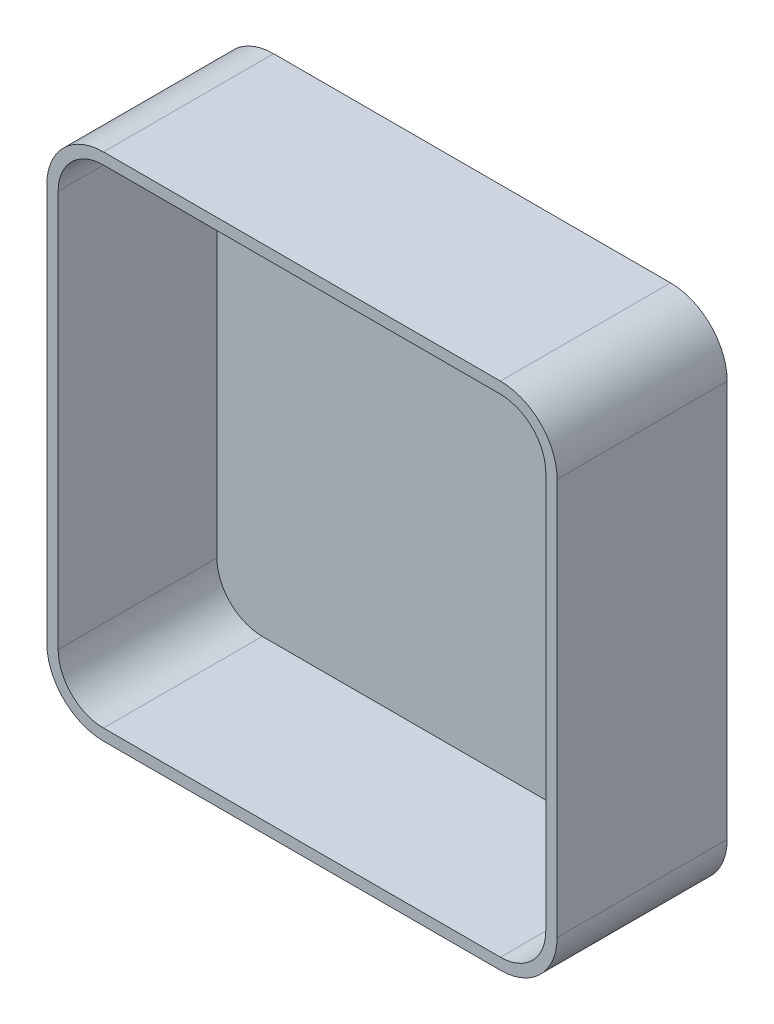
from build123d import *

# Parameters (mm, degrees)
SKETCH1_W           = 45
SKETCH1_H           = 45
BOSS_EXTRUDE1_DEPTH = 15
FILLET1_R           = 5
SHELL1_T            = -1


with BuildPart() as part:
    # Sketch1 → Boss-Extrude1 (new body)
    with BuildSketch(Plane.XY):
        with Locations((22.5, 22.5)):
            Rectangle(SKETCH1_W, SKETCH1_H)
    extrude(amount=BOSS_EXTRUDE1_DEPTH)

    # Fillet1
    fillet1_edges = [part.edges().sort_by_distance(p)[0] for p in [
        (0, 45, 7.5),
        (45, 45, 7.5),
        (45, 0, 7.5),
        (0, 0, 7.5),
    ]]
    fillet(fillet1_edges, radius=FILLET1_R)

    # Shell1
    shell1_openings = [part.faces().sort_by_distance(p)[0] for p in [
        (22.5, 22.5, 15),
    ]]
    offset(amount=SHELL1_T, openings=shell1_openings, kind=Kind.INTERSECTION)


solid = part.part
